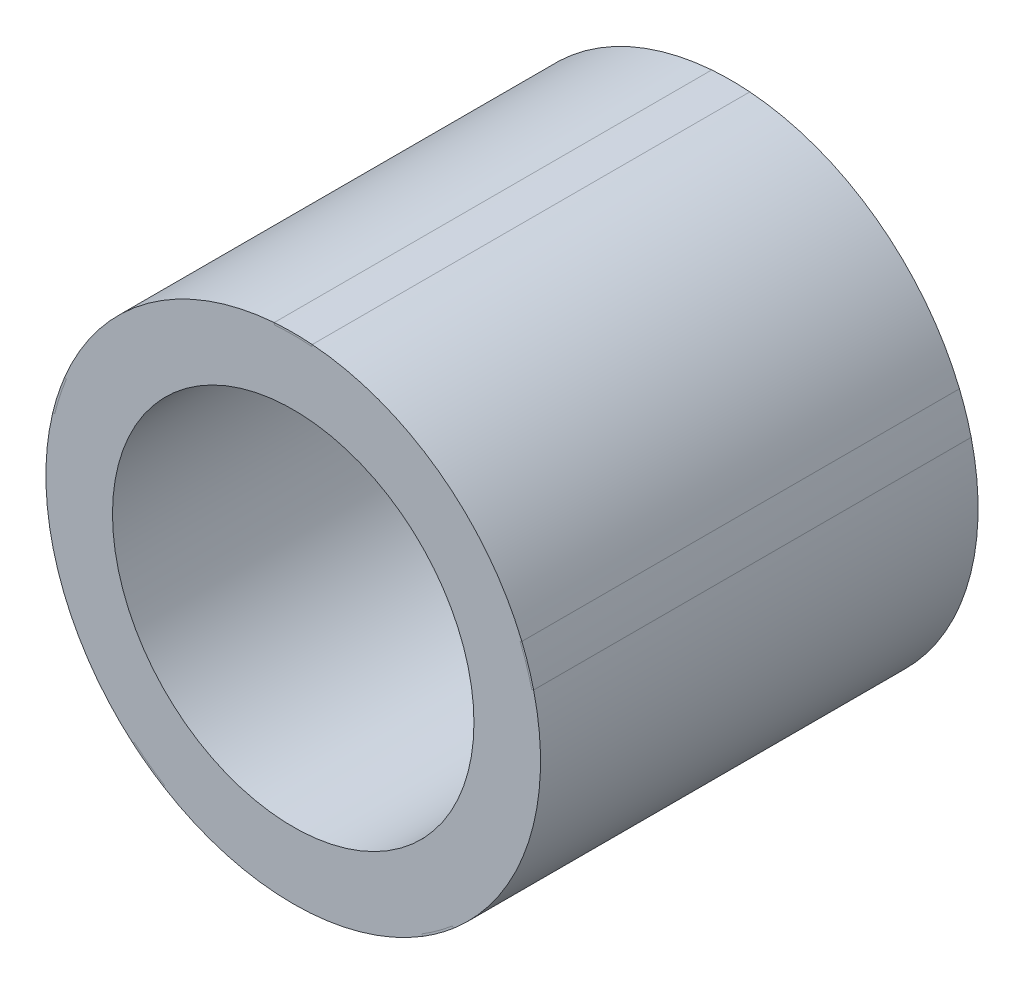
from build123d import *

# Parameters (mm, degrees)
SKETCH1_R           = 13
SKETCH1_R_2         = 9.5
EXTRUDE_THIN1_DEPTH = 11.5
CUT_EXTRUDE1_DEPTH  = 22.685248442
BOSS_EXTRUDE1_DEPTH = 11.5
CIRPATTERN1_COUNT   = 5
CIRPATTERN3_COUNT   = 5


with BuildPart() as part:
    # Sketch1 → Extrude-Thin1 (new, symmetric)
    with BuildSketch(Plane.XY):
        Circle(SKETCH1_R)
        Circle(SKETCH1_R_2, mode=Mode.SUBTRACT)
    extrude(amount=EXTRUDE_THIN1_DEPTH, both=True)

    # Sketch2 → Cut-Extrude1 (cut, symmetric)
    with BuildSketch(Plane.XY):
        with BuildLine():
            Line((1, 12.961481397), (0.992307692, 12.861777694))
            ThreePointArc((0.992307692, 12.861777694), (0, 12.9), (-0.992307692, 12.861777694))
            Line((-0.992307692, 12.861777694), (-1, 12.961481397))
            ThreePointArc((-1, 12.961481397), (0, 13), (1, 12.961481397))
        make_face()
    cut_extrude1 = extrude(amount=CUT_EXTRUDE1_DEPTH, both=True, mode=Mode.SUBTRACT)

    # CirPattern1: Cut-Extrude1 ×5 about axis
    cirpattern1_axis = Axis((0, 0, -13.2), (0, 0, 1))
    for i in range(1, CIRPATTERN1_COUNT):
        add(cut_extrude1.rotate(cirpattern1_axis, i * 360 / CIRPATTERN1_COUNT), mode=Mode.SUBTRACT)


with BuildPart() as body_2:
    # Sketch2_2 → Boss-Extrude1 (new, symmetric)
    with BuildSketch(Plane.XY):
        with BuildLine():
            Line((1, 12.961481397), (0.992307692, 12.861777694))
            ThreePointArc((0.992307692, 12.861777694), (0, 12.9), (-0.992307692, 12.861777694))
            Line((-0.992307692, 12.861777694), (-1, 12.961481397))
            ThreePointArc((-1, 12.961481397), (0, 13), (1, 12.961481397))
        make_face()
    extrude(amount=BOSS_EXTRUDE1_DEPTH, both=True)


with BuildPart() as cirpattern3_1:
    # CirPattern3: pattern copy
    add(body_2.part.rotate(Axis((0, 0, -13.2), (0, 0, 1)), 1 * 360 / CIRPATTERN3_COUNT))


with BuildPart() as cirpattern3_2:
    # CirPattern3: pattern copy
    add(body_2.part.rotate(Axis((0, 0, -13.2), (0, 0, 1)), 2 * 360 / CIRPATTERN3_COUNT))


with BuildPart() as cirpattern3_3:
    # CirPattern3: pattern copy
    add(body_2.part.rotate(Axis((0, 0, -13.2), (0, 0, 1)), 3 * 360 / CIRPATTERN3_COUNT))


with BuildPart() as cirpattern3_4:
    # CirPattern3: pattern copy
    add(body_2.part.rotate(Axis((0, 0, -13.2), (0, 0, 1)), 4 * 360 / CIRPATTERN3_COUNT))


solid = Compound([part.part, body_2.part, cirpattern3_1.part, cirpattern3_2.part, cirpattern3_3.part, cirpattern3_4.part])
